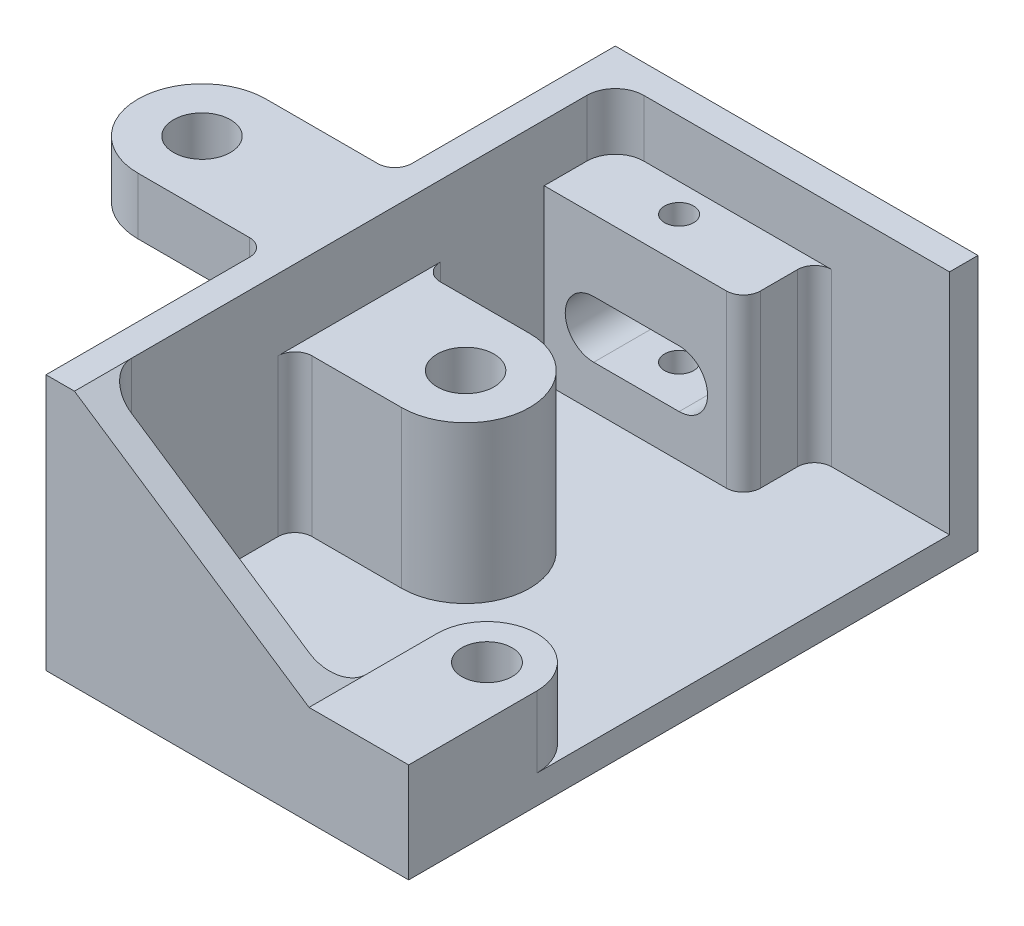
from build123d import *

# Parameters (mm, degrees)
BOSS_EXTRUDE1_DEPTH = 6.35
BOSS_EXTRUDE2_DEPTH = 57.15
FILLET1_R           = 6.35
SKETCH3_R           = 5.6007
BOSS_EXTRUDE3_DEPTH = 22.225
SKETCH4_W           = 127
SKETCH4_H           = 6.35
BOSS_EXTRUDE4_DEPTH = 80.899
BOSS_EXTRUDE5_DEPTH = 38.1
FILLET2_R           = 3.81
SKETCH6_R           = 6.35
BOSS_EXTRUDE6_DEPTH = 34.925
SKETCH7_R           = 6.35
CUT_EXTRUDE1_DEPTH  = 34.925
SKETCH8_R           = 11.1125
CUT_EXTRUDE2_DEPTH  = 3.175
FILLET3_R           = 6.35
SKETCH10_R          = 6.35
BOSS_EXTRUDE7_DEPTH = 12.7
FILLET4_R           = 3.81
CUT_EXTRUDE3_REACH  = 46.45
SKETCH11_R          = 3.241727166
CUT_EXTRUDE4_REACH  = 129


with BuildPart() as part:
    # Sketch1 → Boss-Extrude1 (new body)
    with BuildSketch(Plane.XY):
        Polygon((-25.588082164, 20.346341683), (-31.938082164, 20.346341683), (-31.938082164, -36.803658317), (48.960917836, -36.803658317), (48.960917836, -14.578658317), (26.735917836, -14.578658317), align=None)
    extrude(amount=-BOSS_EXTRUDE1_DEPTH)

    # Sketch2 → Boss-Extrude2 (add)
    with BuildSketch(Plane(origin=(0, 20.346341683, 0), x_dir=(1, 0, 0), z_dir=(0, 1, 0))):
        Polygon((48.960917836, 127), (48.960917836, 120.65), (-25.588082164, 120.65), (-25.588082164, 6.35), (-31.938082164, 6.35), (-31.938082164, 127), (-25.588082164, 127), align=None)
    extrude(amount=-BOSS_EXTRUDE2_DEPTH)

    # Fillet1
    fillet1_edges = [part.edges().sort_by_distance(p)[0] for p in [
        (-25.588082164, -8.228658317, -120.65),
        (-25.588082164, -8.228658317, -6.35),
    ]]
    fillet(fillet1_edges, radius=FILLET1_R)

    # Sketch3 → Boss-Extrude3 (add)
    with BuildSketch(Plane(origin=(0, -14.578658317, 0), x_dir=(1, 0, 0), z_dir=(0, 1, 0))):
        with BuildLine():
            Line((26.735917836, 6.35), (48.960917836, 6.35))
            Line((48.960917836, 6.35), (48.960917836, 28.575))
            ThreePointArc((48.960917836, 28.575), (37.848417836, 39.6875), (26.735917836, 28.575))
            Line((26.735917836, 28.575), (26.735917836, 6.35))
        make_face()
        with Locations((37.848417836, 28.575)):
            Circle(SKETCH3_R, mode=Mode.SUBTRACT)
    extrude(amount=-BOSS_EXTRUDE3_DEPTH)

    # Sketch4 → Boss-Extrude4 (add)
    with BuildSketch(Plane(origin=(48.960917836, 0, 0), x_dir=(0, 0, -1), z_dir=(1, 0, 0))):
        with Locations((63.5, -33.628658317)):
            Rectangle(SKETCH4_W, SKETCH4_H)
    extrude(amount=-BOSS_EXTRUDE4_DEPTH)

    # Sketch5 → Boss-Extrude5 (add)
    with BuildSketch(Plane(origin=(0, -30.453658317, 0), x_dir=(1, 0, 0), z_dir=(0, 1, 0))):
        with BuildLine():
            Line((-25.588082164, 104.775), (18.861917836, 104.775))
            Line((18.861917836, 104.775), (18.861917836, 120.65))
            Line((18.861917836, 120.65), (-19.238082164, 120.65))
            ThreePointArc((-19.238082164, 120.65), (-23.728210225, 118.790128061), (-25.588082164, 114.3))
            Line((-25.588082164, 114.3), (-25.588082164, 104.775))
        make_face()
    extrude(amount=BOSS_EXTRUDE5_DEPTH)

    # Fillet2
    fillet2_edges = [part.edges().sort_by_distance(p)[0] for p in [
        (18.861917836, -11.403658317, -104.775),
        (18.861917836, -11.403658317, -120.65),
    ]]
    fillet(fillet2_edges, radius=FILLET2_R)

    # Sketch6 → Boss-Extrude6 (add)
    with BuildSketch(Plane(origin=(0, -30.453658317, 0), x_dir=(1, 0, 0), z_dir=(0, 1, 0))):
        with BuildLine():
            Line((-1.839082164, 77.8002), (-25.588082164, 77.8002))
            Line((-25.588082164, 77.8002), (-25.588082164, 49.1998))
            Line((-25.588082164, 49.1998), (-1.839082164, 49.1998))
            ThreePointArc((-1.839082164, 49.1998), (12.461117836, 63.5), (-1.839082164, 77.8002))
        make_face()
        with Locations((-1.839082164, 63.5)):
            Circle(SKETCH6_R, mode=Mode.SUBTRACT)
    extrude(amount=BOSS_EXTRUDE6_DEPTH)

    # Sketch7 → Cut-Extrude1 (cut)
    with BuildSketch(Plane(origin=(0, -30.453658317, 0), x_dir=(1, 0, 0), z_dir=(0, 1, 0))):
        with Locations((-1.839082164, 63.5)):
            Circle(SKETCH7_R)
    extrude(amount=-CUT_EXTRUDE1_DEPTH, mode=Mode.SUBTRACT)

    # Sketch8 → Cut-Extrude2 (cut)
    with BuildSketch(Plane.XZ.offset(36.803658317)):
        with Locations((-1.839082164, -63.5)):
            Circle(SKETCH8_R)
    extrude(amount=-CUT_EXTRUDE2_DEPTH, mode=Mode.SUBTRACT)

    # Fillet3
    fillet3_edges = [part.edges().sort_by_distance(p)[0] for p in [
        (26.735917836, -22.516158317, -6.35),
    ]]
    fillet(fillet3_edges, radius=FILLET3_R)

    # Sketch10 → Boss-Extrude7 (add)
    with BuildSketch(Plane(origin=(0, 20.346341683, 0), x_dir=(1, 0, 0), z_dir=(0, 1, 0))):
        with BuildLine():
            Line((-60.640082164, 49.1998), (-31.938082164, 49.1998))
            Line((-31.938082164, 49.1998), (-31.938082164, 77.8002))
            Line((-31.938082164, 77.8002), (-60.640082164, 77.8002))
            ThreePointArc((-60.640082164, 77.8002), (-74.940282164, 63.5), (-60.640082164, 49.1998))
        make_face()
        with Locations((-60.640082164, 63.5)):
            Circle(SKETCH10_R, mode=Mode.SUBTRACT)
    extrude(amount=-BOSS_EXTRUDE7_DEPTH)

    # Fillet4
    fillet4_edges = [part.edges().sort_by_distance(p)[0] for p in [
        (-25.588082164, -12.991158317, -77.8002),
        (-25.588082164, -12.991158317, -49.1998),
        (-31.938082164, 13.996341683, -77.8002),
        (-31.938082164, 13.996341683, -49.1998),
    ]]
    fillet(fillet4_edges, radius=FILLET4_R)

    # Sketch11 → Cut-Extrude3 (cut, up to next)
    with BuildSketch(Plane(origin=(0, 7.646341683, 0), x_dir=(1, 0, 0), z_dir=(0, 1, 0)), mode=Mode.PRIVATE) as cut_extrude3_sk1:
        with Locations((-5.014082164, 114.3)):
            Circle(SKETCH11_R)
    cut_extrude3_tool1 = extrude(cut_extrude3_sk1.sketch, amount=-CUT_EXTRUDE3_REACH, mode=Mode.PRIVATE) & part.part
    add(cut_extrude3_tool1.solids().sort_by_distance((-5.014082, 7.646342, -114.3))[0], mode=Mode.SUBTRACT)

    # Sketch12 → Cut-Extrude4 (cut, up to next)
    with BuildSketch(Plane(origin=(0, 0, -127), x_dir=(-1, 0, 0), z_dir=(0, 0, -1)), mode=Mode.PRIVATE) as cut_extrude4_sk1:
        with BuildLine():
            Line((-4.510928423, -8.228658317), (14.539060991, -8.228658317))
            ThreePointArc((14.539060991, -8.228658317), (20.889071577, -14.578653023), (14.539071577, -20.928658317))
            Line((14.539071577, -20.928658317), (-4.510907248, -20.928658317))
            ThreePointArc((-4.510907248, -20.928658317), (-10.860928423, -14.578668904), (-4.510928423, -8.228658317))
        make_face()
    cut_extrude4_tool1 = extrude(cut_extrude4_sk1.sketch, amount=-CUT_EXTRUDE4_REACH, mode=Mode.PRIVATE) & part.part
    add(cut_extrude4_tool1.solids().sort_by_distance((-5.014072, -14.578658, -127))[0], mode=Mode.SUBTRACT)


solid = part.part
